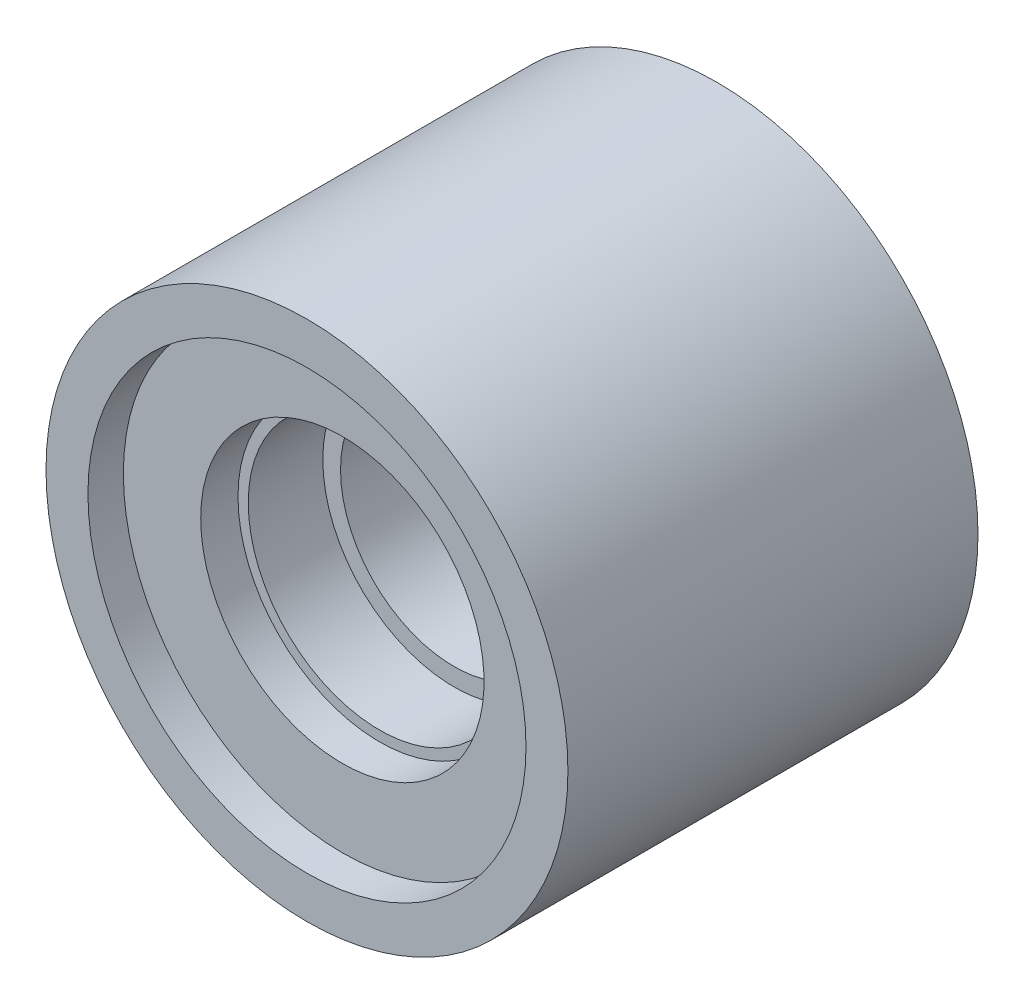
from build123d import *

# Parameters (mm, degrees)
SKETCH_1_R          = 14
EXTRUDE_1_DEPTH     = 22
SKETCH_2_R          = 2.95
CUT_EXTRUDE_1_DEPTH = 1.1
SKETCH_3_R          = 2.6
CUT_EXTRUDE_2_DEPTH = 9
SKETCH_5_R          = 6.1
CUT_EXTRUDE_3_DEPTH = 11.9
SKETCH_6_R          = 7.05
CUT_EXTRUDE_4_DEPTH = 7.9
SKETCH_7_R          = 7.6
CUT_EXTRUDE_5_DEPTH = 3.9
SKETCH_8_R          = 11.75
CUT_EXTRUDE_6_DEPTH = 1.9


with BuildPart() as part:
    # Эскиз1 → Бобышка-Вытянуть1 (new body)
    with BuildSketch(Plane.XY):
        Circle(SKETCH_1_R)
    extrude(amount=EXTRUDE_1_DEPTH)

    # Эскиз2 → Вырез-Вытянуть1 (cut)
    with BuildSketch(Plane(origin=(0, 0, 0), x_dir=(-1, 0, 0), z_dir=(0, 0, -1))):
        Circle(SKETCH_2_R)
    extrude(amount=-CUT_EXTRUDE_1_DEPTH, mode=Mode.SUBTRACT)

    # Эскиз3 → Вырез-Вытянуть2 (cut)
    with BuildSketch(Plane(origin=(0, 0, 1.1), x_dir=(-1, 0, 0), z_dir=(0, 0, -1))):
        Circle(SKETCH_3_R)
    extrude(amount=-CUT_EXTRUDE_2_DEPTH, mode=Mode.SUBTRACT)

    # Эскиз5 → Вырез-Вытянуть3 (cut)
    with BuildSketch(Plane.XY.offset(22)):
        Circle(SKETCH_5_R)
    extrude(amount=-CUT_EXTRUDE_3_DEPTH, mode=Mode.SUBTRACT)

    # Эскиз6 → Вырез-Вытянуть4 (cut)
    with BuildSketch(Plane.XY.offset(22)):
        Circle(SKETCH_6_R)
    extrude(amount=-CUT_EXTRUDE_4_DEPTH, mode=Mode.SUBTRACT)

    # Эскиз7 → Вырез-Вытянуть5 (cut)
    with BuildSketch(Plane.XY.offset(22)):
        Circle(SKETCH_7_R)
    extrude(amount=-CUT_EXTRUDE_5_DEPTH, mode=Mode.SUBTRACT)

    # Эскиз8 → Вырез-Вытянуть6 (cut)
    with BuildSketch(Plane.XY.offset(22)):
        Circle(SKETCH_8_R)
    extrude(amount=-CUT_EXTRUDE_6_DEPTH, mode=Mode.SUBTRACT)


solid = part.part
